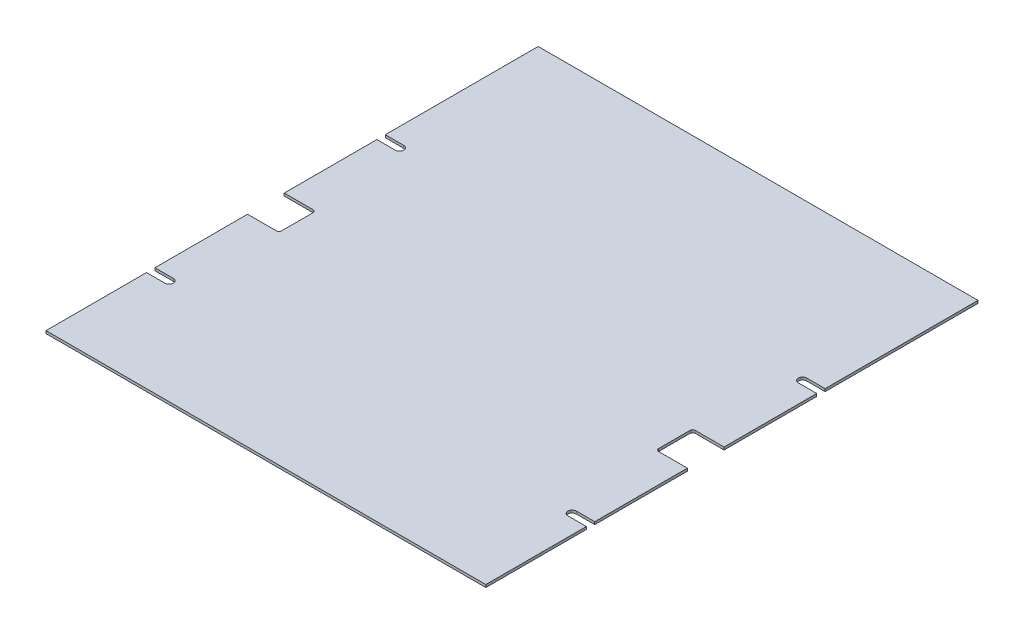
from build123d import *

# Parameters (mm, degrees)
SKETCH1_W           = 533.4
SKETCH1_H           = 596.9
BOSS_EXTRUDE1_DEPTH = 3.175
SKETCH8_W           = 38.1
SKETCH8_H           = 44.45
CUT_EXTRUDE2_DEPTH  = 4.175
FILLET1_R           = 3.175
CUT_EXTRUDE3_DEPTH  = 4.175


with BuildPart() as part:
    # Sketch1 → Boss-Extrude1 (new body)
    with BuildSketch(Plane(origin=(0, 0, 0), x_dir=(1, 0, 0), z_dir=(0, 1, 0))):
        Rectangle(SKETCH1_W, SKETCH1_H)
    extrude(amount=BOSS_EXTRUDE1_DEPTH)

    # Sketch8 → Cut-Extrude2 (cut, through all)
    with BuildSketch(Plane.XZ):
        with Locations((-247.65, 31.75)):
            Rectangle(SKETCH8_W, SKETCH8_H)
        with Locations((247.65, 31.75)):
            Rectangle(SKETCH8_W, SKETCH8_H)
    extrude(amount=-CUT_EXTRUDE2_DEPTH, mode=Mode.SUBTRACT)

    # Fillet1
    fillet1_edges = [part.edges().sort_by_distance(p)[0] for p in [
        (-228.6, 1.5875, 53.975),
        (-228.6, 1.5875, 9.525),
        (228.6, 1.5875, 9.525),
        (228.6, 1.5875, 53.975),
    ]]
    fillet(fillet1_edges, radius=FILLET1_R)

    # Sketch9 → Cut-Extrude3 (cut, through all)
    with BuildSketch(Plane.XZ):
        with BuildLine():
            Line((-266.7, 176.530000343), (-244.3861, 176.530000343))
            ThreePointArc((-244.3861, 176.530000343), (-239.3061, 171.450000343), (-244.3861, 166.370000343))
            Line((-244.3861, 166.370000343), (-266.7, 166.370000343))
            ThreePointArc((-266.7, 166.370000343), (-271.78, 171.450000343), (-266.7, 176.530000343))
        make_face()
        with BuildLine():
            Line((-266.7, -113.030000343), (-244.3861, -113.030000343))
            ThreePointArc((-244.3861, -113.030000343), (-239.3061, -107.950000343), (-244.3861, -102.870000343))
            Line((-244.3861, -102.870000343), (-266.7, -102.870000343))
            ThreePointArc((-266.7, -102.870000343), (-271.78, -107.950000343), (-266.7, -113.030000343))
        make_face()
        with BuildLine():
            Line((266.7, 176.530000343), (244.3861, 176.530000343))
            ThreePointArc((244.3861, 176.530000343), (239.3061, 171.450000343), (244.3861, 166.370000343))
            Line((244.3861, 166.370000343), (266.7, 166.370000343))
            ThreePointArc((266.7, 166.370000343), (271.78, 171.450000343), (266.7, 176.530000343))
        make_face()
        with BuildLine():
            Line((266.7, -113.030000343), (244.3861, -113.030000343))
            ThreePointArc((244.3861, -113.030000343), (239.3061, -107.950000343), (244.3861, -102.870000343))
            Line((244.3861, -102.870000343), (266.7, -102.870000343))
            ThreePointArc((266.7, -102.870000343), (271.78, -107.950000343), (266.7, -113.030000343))
        make_face()
    extrude(amount=-CUT_EXTRUDE3_DEPTH, mode=Mode.SUBTRACT)


solid = part.part
